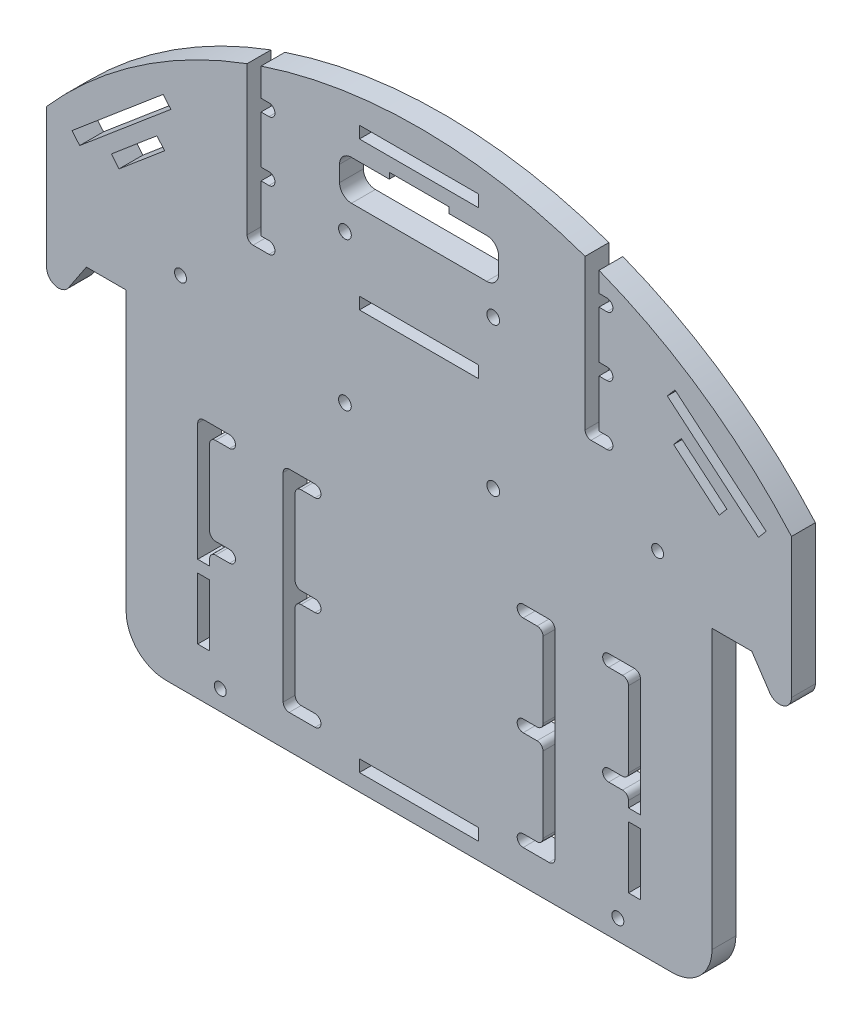
from build123d import *

# Parameters (mm, degrees)
BOSS_EXTRUDE1_DEPTH = 6
CUT_EXTRUDE1_DEPTH  = 6
CUT_EXTRUDE2_DEPTH  = 6
SKETCH4_R           = 1.5
CUT_EXTRUDE3_DEPTH  = 6
CUT_EXTRUDE4_DEPTH  = 6
SKETCH6_W           = 30
SKETCH6_H           = 3
CUT_EXTRUDE5_DEPTH  = 6
SKETCH9_W           = 30
SKETCH9_H           = 3
SKETCH9_W_2         = 15
CUT_EXTRUDE8_DEPTH  = 10
CUT_EXTRUDE13_DEPTH = 10
SKETCH15_W          = 9.5
SKETCH15_H          = 4.882720797
SKETCH15_H_2        = 6.067131096
BOSS_EXTRUDE5_DEPTH = 6
BOSS_EXTRUDE2_DEPTH = 6
FILLET1_R           = 10
SKETCH13_R          = 1.6
CUT_EXTRUDE11_DEPTH = 6
SKETCH14_W          = 30
SKETCH14_H          = 3
CUT_EXTRUDE12_DEPTH = 6
FILLET2_R           = 3
FILLET3_R           = 1.5
SKETCH16_W          = 3
SKETCH16_H          = 1.5
SKETCH16_H_2        = 2.715915128
CUT_EXTRUDE14_DEPTH = 6
SKETCH17_W          = 3
SKETCH17_H          = 3
BOSS_EXTRUDE6_DEPTH = 6


with BuildPart() as part:
    # Sketch1 → Boss-Extrude1 (new body)
    with BuildSketch(Plane.XY):
        with BuildLine():
            Line((-73.674969976, -35), (73.674969976, -35))
            Line((73.674969976, -35), (73.674969976, 35))
            Line((73.674969976, 35), (93.674969976, 35))
            Line((93.674969976, 35), (93.674969976, 82.764726786))
            ThreePointArc((93.674969976, 82.764726786), (0, 125), (-93.674969976, 82.764726786))
            Line((-93.674969976, 82.764726786), (-93.674969976, 35))
            Line((-93.674969976, 35), (-73.674969976, 35))
            Line((-73.674969976, 35), (-73.674969976, -35))
        make_face()
    extrude(amount=BOSS_EXTRUDE1_DEPTH)

    # Sketch2 → Cut-Extrude1 (cut)
    with BuildSketch(Plane.XY.offset(6)):
        with BuildLine():
            Line((-37.75, 78.5), (-39.75, 78.5))
            Line((-39.75, 78.5), (-43.25, 78.5))
            Line((-43.25, 78.5), (-43.25, 119.029429271))
            Line((-43.25, 119.029429271), (-39.75, 119.029429271))
            Line((-39.75, 119.029429271), (-39.75, 111.5))
            Line((-39.75, 111.5), (-39.25, 111.5))
            Line((-39.25, 111.5), (-37.75, 111.5))
            ThreePointArc((-37.75, 111.5), (-36.25, 110), (-37.75, 108.5))
            Line((-37.75, 108.5), (-39.25, 108.5))
            Line((-39.25, 108.5), (-39.75, 108.5))
            Line((-39.75, 108.5), (-39.75, 96.5))
            Line((-39.75, 96.5), (-39.25, 96.5))
            Line((-39.25, 96.5), (-37.75, 96.5))
            ThreePointArc((-37.75, 96.5), (-36.25, 95), (-37.75, 93.5))
            Line((-37.75, 93.5), (-39.25, 93.5))
            Line((-39.25, 93.5), (-39.75, 93.5))
            Line((-39.75, 93.5), (-39.75, 81.5))
            Line((-39.75, 81.5), (-39.25, 81.5))
            Line((-39.25, 81.5), (-37.75, 81.5))
            ThreePointArc((-37.75, 81.5), (-36.25, 80), (-37.75, 78.5))
        make_face()
        with BuildLine():
            Line((41.75, 119.029429271), (41.75, 119.62073818))
            Line((41.75, 119.62073818), (45.25, 119.62073818))
            Line((45.25, 119.62073818), (45.25, 119.029429271))
            Line((45.25, 119.029429271), (45.25, 111.5))
            Line((45.25, 111.5), (47.25, 111.5))
            ThreePointArc((47.25, 111.5), (48.75, 110), (47.25, 108.5))
            Line((47.25, 108.5), (45.25, 108.5))
            Line((45.25, 108.5), (45.25, 96.5))
            Line((45.25, 96.5), (47.25, 96.5))
            ThreePointArc((47.25, 96.5), (48.75, 95), (47.25, 93.5))
            Line((47.25, 93.5), (45.25, 93.5))
            Line((45.25, 93.5), (45.25, 81.5))
            Line((45.25, 81.5), (47.25, 81.5))
            ThreePointArc((47.25, 81.5), (48.75, 80), (47.25, 78.5))
            Line((47.25, 78.5), (41.75, 78.5))
            Line((41.75, 78.5), (41.75, 119.029429271))
        make_face()
    extrude(amount=-CUT_EXTRUDE1_DEPTH, mode=Mode.SUBTRACT)

    # Sketch3 → Cut-Extrude2 (cut)
    with BuildSketch(Plane.XY.offset(6)):
        Polygon((93.674969976, 52.764726786), (73.674969976, 52.764726786), (73.674969976, -27.235273214), (-73.674969976, -27.235273214), (-73.674969976, 52.764726786), (-93.674969976, 52.764726786), (-93.674969976, -16.117636607), (-93.674969976, -35), (-73.674969976, -35), (73.674969976, -35), (93.674969976, -35), (93.674969976, -16.117636607), align=None)
    extrude(amount=-CUT_EXTRUDE2_DEPTH, mode=Mode.SUBTRACT)

    # Sketch4 → Cut-Extrude3 (cut)
    with BuildSketch(Plane.XY.offset(6)):
        with Locations((50, -22.235273214)):
            Circle(SKETCH4_R)
        with Locations((-50, -22.235273214)):
            Circle(SKETCH4_R)
        with Locations((60, 62.764726786)):
            Circle(SKETCH4_R)
        with Locations((-60, 62.764726786)):
            Circle(SKETCH4_R)
    extrude(amount=-CUT_EXTRUDE3_DEPTH, mode=Mode.SUBTRACT)

    # Sketch5 → Cut-Extrude4 (cut)
    with BuildSketch(Plane.XY.offset(6)):
        with BuildLine():
            Line((-17, 110), (17, 110))
            ThreePointArc((17, 110), (19.121320344, 109.121320344), (20, 107))
            Line((20, 107), (20, 103))
            ThreePointArc((20, 103), (19.121320344, 100.878679656), (17, 100))
            Line((17, 100), (-17, 100))
            ThreePointArc((-17, 100), (-19.121320344, 100.878679656), (-20, 103))
            Line((-20, 103), (-20, 107))
            ThreePointArc((-20, 107), (-19.121320344, 109.121320344), (-17, 110))
        make_face()
    extrude(amount=-CUT_EXTRUDE4_DEPTH, mode=Mode.SUBTRACT)

    # Sketch6 → Cut-Extrude5 (cut)
    with BuildSketch(Plane(origin=(0, 0, 0), x_dir=(-1, 0, 0), z_dir=(0, 0, -1))):
        with Locations((0, 79.264726786)):
            Rectangle(SKETCH6_W, SKETCH6_H)
    extrude(amount=-CUT_EXTRUDE5_DEPTH, mode=Mode.SUBTRACT)

    # Sketch9 → Cut-Extrude8 (cut)
    with BuildSketch(Plane.XY.offset(6)):
        with Locations((0, 116.5)):
            Rectangle(SKETCH9_W, SKETCH9_H)
        Polygon((64.364341028, 100.029951634), (87.294606331, 80.68562603), (85.360173771, 78.392599499), (62.429908467, 97.736925104), align=None)
        Polygon((-87.294606331, 80.68562603), (-85.360173771, 78.392599499), (-62.429908467, 97.736925104), (-64.364341028, 100.029951634), align=None)
        Polygon((65.960254421, 90.262625118), (77.422828052, 80.587429732), (75.487788974, 78.294915006), (64.025215344, 87.970110392), align=None)
        with Locations((0, 110)):
            Rectangle(SKETCH9_W_2, SKETCH9_H)
        Polygon((-77.394030345, 80.552769808), (-65.932380202, 90.22905918), (-63.997122328, 87.936729151), (-75.458772471, 78.26043978), align=None)
    extrude(amount=-CUT_EXTRUDE8_DEPTH, mode=Mode.SUBTRACT)

    # Sketch11 → Cut-Extrude13 (cut)
    with BuildSketch(Plane.XY.offset(6)):
        with BuildLine():
            Line((-26.174969976, -18.735273214), (-32.674969976, -18.735273214))
            ThreePointArc((-32.674969976, -18.735273214), (-33.735630148, -18.295933386), (-34.174969976, -17.235273214))
            Line((-34.174969976, -17.235273214), (-34.174969976, 32.764726786))
            ThreePointArc((-34.174969976, 32.764726786), (-33.735630148, 33.825386958), (-32.674969976, 34.264726786))
            Line((-32.674969976, 34.264726786), (-26.174969976, 34.264726786))
            ThreePointArc((-26.174969976, 34.264726786), (-24.674969976, 32.764726786), (-26.174969976, 31.264726786))
            Line((-26.174969976, 31.264726786), (-29.674969976, 31.264726786))
            ThreePointArc((-29.674969976, 31.264726786), (-30.735630148, 30.825386958), (-31.174969976, 29.764726786))
            Line((-31.174969976, 29.764726786), (-31.174969976, 10.764726786))
            ThreePointArc((-31.174969976, 10.764726786), (-30.735630148, 9.704066614), (-29.674969976, 9.264726786))
            Line((-29.674969976, 9.264726786), (-26.174969976, 9.264726786))
            ThreePointArc((-26.174969976, 9.264726786), (-24.674969976, 7.764726786), (-26.174969976, 6.264726786))
            Line((-26.174969976, 6.264726786), (-29.674969976, 6.264726786))
            ThreePointArc((-29.674969976, 6.264726786), (-30.735630148, 5.825386958), (-31.174969976, 4.764726786))
            Line((-31.174969976, 4.764726786), (-31.174969976, -14.235273214))
            ThreePointArc((-31.174969976, -14.235273214), (-30.735630148, -15.295933386), (-29.674969976, -15.735273214))
            Line((-29.674969976, -15.735273214), (-26.174969976, -15.735273214))
            ThreePointArc((-26.174969976, -15.735273214), (-24.674969976, -17.235273214), (-26.174969976, -18.735273214))
        make_face()
        with BuildLine():
            Line((34.174969976, -17.235273214), (34.174969976, 32.764726786))
            ThreePointArc((34.174969976, 32.764726786), (33.735630148, 33.825386958), (32.674969976, 34.264726786))
            Line((32.674969976, 34.264726786), (26.174969976, 34.264726786))
            ThreePointArc((26.174969976, 34.264726786), (24.674969976, 32.764726786), (26.174969976, 31.264726786))
            Line((26.174969976, 31.264726786), (29.674969976, 31.264726786))
            ThreePointArc((29.674969976, 31.264726786), (30.735630148, 30.825386958), (31.174969976, 29.764726786))
            Line((31.174969976, 29.764726786), (31.174969976, 10.764726786))
            ThreePointArc((31.174969976, 10.764726786), (30.735630148, 9.704066614), (29.674969976, 9.264726786))
            Line((29.674969976, 9.264726786), (26.174969976, 9.264726786))
            ThreePointArc((26.174969976, 9.264726786), (24.674969976, 7.764726786), (26.174969976, 6.264726786))
            Line((26.174969976, 6.264726786), (29.674969976, 6.264726786))
            ThreePointArc((29.674969976, 6.264726786), (30.735630148, 5.825386958), (31.174969976, 4.764726786))
            Line((31.174969976, 4.764726786), (31.174969976, -14.235273214))
            ThreePointArc((31.174969976, -14.235273214), (30.735630148, -15.295933386), (29.674969976, -15.735273214))
            Line((29.674969976, -15.735273214), (26.174969976, -15.735273214))
            ThreePointArc((26.174969976, -15.735273214), (24.674969976, -17.235273214), (26.174969976, -18.735273214))
            Line((26.174969976, -18.735273214), (32.674969976, -18.735273214))
            ThreePointArc((32.674969976, -18.735273214), (33.735630148, -18.295933386), (34.174969976, -17.235273214))
        make_face()
        with BuildLine():
            Line((55.674969976, -17.235273214), (55.674969976, 32.764726786))
            ThreePointArc((55.674969976, 32.764726786), (55.235630148, 33.825386958), (54.174969976, 34.264726786))
            Line((54.174969976, 34.264726786), (47.674969976, 34.264726786))
            ThreePointArc((47.674969976, 34.264726786), (46.174969976, 32.764726786), (47.674969976, 31.264726786))
            Line((47.674969976, 31.264726786), (51.174969976, 31.264726786))
            ThreePointArc((51.174969976, 31.264726786), (52.235630148, 30.825386958), (52.674969976, 29.764726786))
            Line((52.674969976, 29.764726786), (52.674969976, 10.764726786))
            ThreePointArc((52.674969976, 10.764726786), (52.235630148, 9.704066614), (51.174969976, 9.264726786))
            Line((51.174969976, 9.264726786), (47.674969976, 9.264726786))
            ThreePointArc((47.674969976, 9.264726786), (46.174969976, 7.764726786), (47.674969976, 6.264726786))
            Line((47.674969976, 6.264726786), (51.174969976, 6.264726786))
            ThreePointArc((51.174969976, 6.264726786), (52.235630148, 5.825386958), (52.674969976, 4.764726786))
            Line((52.674969976, 4.764726786), (52.674969976, -14.235273214))
            ThreePointArc((52.674969976, -14.235273214), (52.235630148, -15.295933386), (51.174969976, -15.735273214))
            Line((51.174969976, -15.735273214), (47.674969976, -15.735273214))
            ThreePointArc((47.674969976, -15.735273214), (46.174969976, -17.235273214), (47.674969976, -18.735273214))
            Line((47.674969976, -18.735273214), (54.174969976, -18.735273214))
            ThreePointArc((54.174969976, -18.735273214), (55.235630148, -18.295933386), (55.674969976, -17.235273214))
        make_face()
        with BuildLine():
            Line((-55.674969976, -17.235273214), (-55.674969976, 32.764726786))
            ThreePointArc((-55.674969976, 32.764726786), (-55.235630148, 33.825386958), (-54.174969976, 34.264726786))
            Line((-54.174969976, 34.264726786), (-47.674969976, 34.264726786))
            ThreePointArc((-47.674969976, 34.264726786), (-46.174969976, 32.764726786), (-47.674969976, 31.264726786))
            Line((-47.674969976, 31.264726786), (-51.174969976, 31.264726786))
            ThreePointArc((-51.174969976, 31.264726786), (-52.235630148, 30.825386958), (-52.674969976, 29.764726786))
            Line((-52.674969976, 29.764726786), (-52.674969976, 10.764726786))
            ThreePointArc((-52.674969976, 10.764726786), (-52.235630148, 9.704066614), (-51.174969976, 9.264726786))
            Line((-51.174969976, 9.264726786), (-47.674969976, 9.264726786))
            ThreePointArc((-47.674969976, 9.264726786), (-46.174969976, 7.764726786), (-47.674969976, 6.264726786))
            Line((-47.674969976, 6.264726786), (-51.174969976, 6.264726786))
            ThreePointArc((-51.174969976, 6.264726786), (-52.235630148, 5.825386958), (-52.674969976, 4.764726786))
            Line((-52.674969976, 4.764726786), (-52.674969976, -14.235273214))
            ThreePointArc((-52.674969976, -14.235273214), (-52.235630148, -15.295933386), (-51.174969976, -15.735273214))
            Line((-51.174969976, -15.735273214), (-47.674969976, -15.735273214))
            ThreePointArc((-47.674969976, -15.735273214), (-46.174969976, -17.235273214), (-47.674969976, -18.735273214))
            Line((-47.674969976, -18.735273214), (-54.174969976, -18.735273214))
            ThreePointArc((-54.174969976, -18.735273214), (-55.235630148, -18.295933386), (-55.674969976, -17.235273214))
        make_face()
    extrude(amount=-CUT_EXTRUDE13_DEPTH, mode=Mode.SUBTRACT)

    # Sketch15 → Boss-Extrude5 (add)
    with BuildSketch(Plane.XY.offset(6)):
        with Locations((-50.924969976, -16.293912816)):
            Rectangle(SKETCH15_W, SKETCH15_H)
        with Locations((50.924969976, -15.701707666)):
            Rectangle(SKETCH15_W, SKETCH15_H_2)
    extrude(amount=-BOSS_EXTRUDE5_DEPTH)

    # Sketch12 → Boss-Extrude2 (add)
    with BuildSketch(Plane.XY.offset(6)):
        Polygon((-93.674969976, 52.764726786), (-93.674969976, 37.764726786), (-83.674969976, 52.764726786), align=None)
        Polygon((83.674969976, 52.764726786), (93.674969976, 52.764726786), (93.674969976, 37.764726786), align=None)
    extrude(amount=-BOSS_EXTRUDE2_DEPTH)

    # Fillet1
    fillet1_edges = [part.edges().sort_by_distance(p)[0] for p in [
        (-73.674969976, -27.235273214, 3),
        (73.674969976, -27.235273214, 3),
    ]]
    fillet(fillet1_edges, radius=FILLET1_R)

    # Sketch13 → Cut-Extrude11 (cut)
    with BuildSketch(Plane(origin=(0, 0, 0), x_dir=(-1, 0, 0), z_dir=(0, 0, -1))):
        with Locations((-18.65, 93)):
            Circle(SKETCH13_R)
        with Locations((18.65, 55.7)):
            Circle(SKETCH13_R)
        with Locations((-18.65, 55.7)):
            Circle(SKETCH13_R)
        with Locations((18.65, 93)):
            Circle(SKETCH13_R)
    extrude(amount=-CUT_EXTRUDE11_DEPTH, mode=Mode.SUBTRACT)

    # Sketch14 → Cut-Extrude12 (cut)
    with BuildSketch(Plane.XY.offset(6)):
        with Locations((0, -21.5)):
            Rectangle(SKETCH14_W, SKETCH14_H)
    extrude(amount=-CUT_EXTRUDE12_DEPTH, mode=Mode.SUBTRACT)

    # Fillet2
    fillet2_edges = [part.edges().sort_by_distance(p)[0] for p in [
        (-93.674969976, 37.764726786, 3),
        (93.674969976, 37.764726786, 3),
    ]]
    fillet(fillet2_edges, radius=FILLET2_R)

    # Fillet3
    fillet3_edges = [part.edges().sort_by_distance(p)[0] for p in [
        (-43.25, 78.5, 3),
        (41.75, 78.5, 3),
    ]]
    fillet(fillet3_edges, radius=FILLET3_R)

    # Sketch16 → Cut-Extrude14 (cut)
    with BuildSketch(Plane.XY.offset(6)):
        with Locations((-54.174969976, -14.602552417)):
            Rectangle(SKETCH16_W, SKETCH16_H)
        with Locations((54.174969976, -14.026099682)):
            Rectangle(SKETCH16_W, SKETCH16_H_2)
    extrude(amount=-CUT_EXTRUDE14_DEPTH, mode=Mode.SUBTRACT)

    # Sketch17 → Boss-Extrude6 (add)
    with BuildSketch(Plane.XY.offset(6)):
        with Locations((-54.174969976, 1.615942754)):
            Rectangle(SKETCH17_W, SKETCH17_H)
        with Locations((54.174969976, 1.615942754)):
            Rectangle(SKETCH17_W, SKETCH17_H)
    extrude(amount=-BOSS_EXTRUDE6_DEPTH)


solid = part.part
